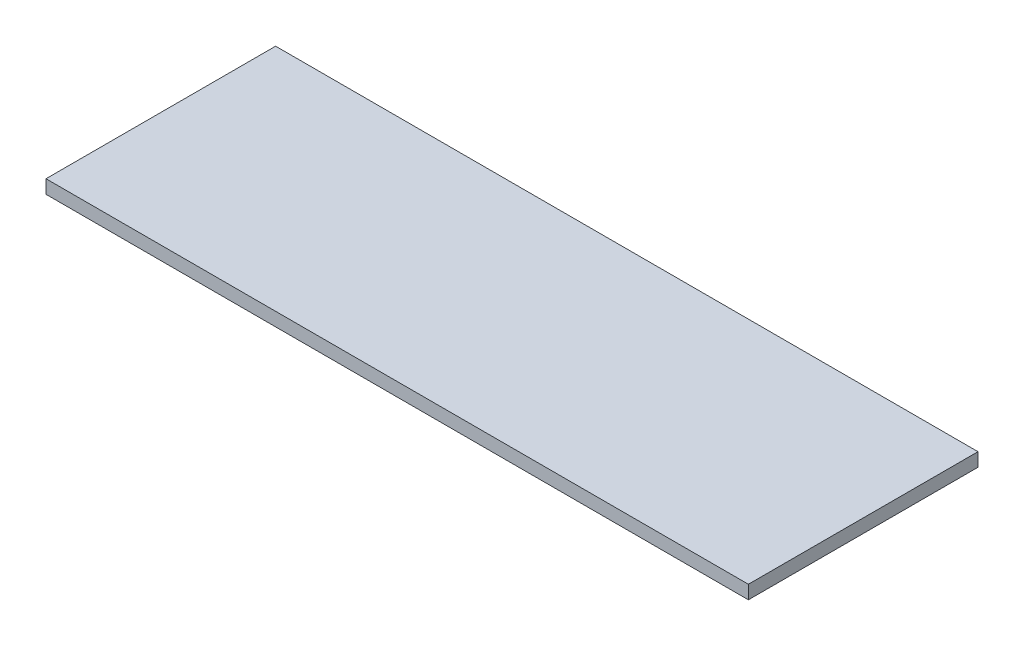
from build123d import *

# Parameters (mm, degrees)
SKETCH1_W           = 52
SKETCH1_H           = 17
BOSS_EXTRUDE1_DEPTH = 1


with BuildPart() as part:
    # Sketch1 → Boss-Extrude1 (new body)
    with BuildSketch(Plane(origin=(0, 0, 0), x_dir=(1, 0, 0), z_dir=(0, 1, 0))):
        with Locations((-3.039750959, -6.8847981)):
            Rectangle(SKETCH1_W, SKETCH1_H)
    extrude(amount=BOSS_EXTRUDE1_DEPTH)


solid = part.part
